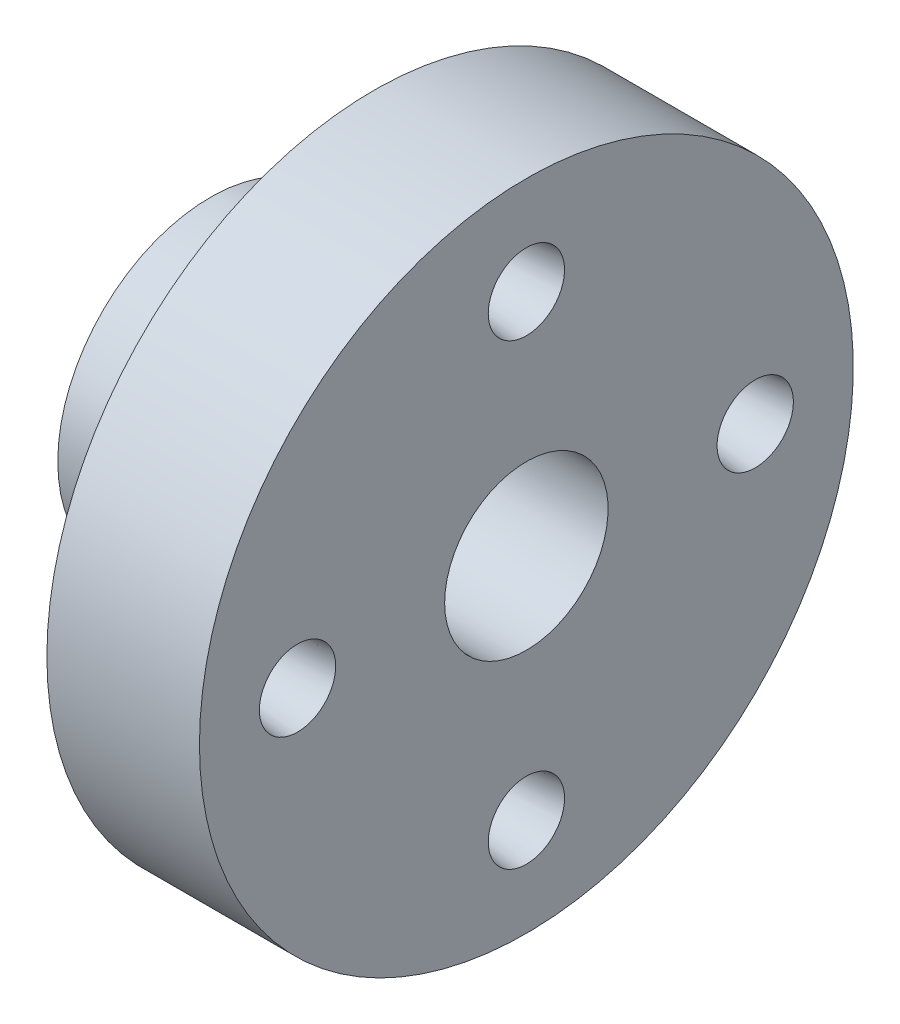
from build123d import *

# Parameters (mm, degrees)
PATTERN_CIRCULAR_2_COUNT = 4


with BuildPart() as part:
    # Эскиз1 → Повернуть1 (revolve)
    with BuildSketch(Plane.XY):
        Polygon((-29, -15), (29, -15), (29, -60), (1, -60), (1, -28), (-29, -28), align=None)
    revolve(axis=Axis((-59.74315319, 0, 0), (1, 0, 0)))

    # Эскиз3 → Вырез-Повернуть1 (revolve, cut)
    with BuildSketch(Plane.XY):
        Polygon((29, 42), (1, 42), (1, 47.7), (16, 47.7), (29, 49), align=None)
    cut_revolve_1 = revolve(axis=Axis((-8.793362521, 42, 0), (1, 0, 0)), mode=Mode.SUBTRACT)

    # Круговой массив2: Вырез-Повернуть1 ×4 about axis
    pattern_circular_2_axis = Axis((0, 0, 0), (1, 0, 0))
    for i in range(1, PATTERN_CIRCULAR_2_COUNT):
        add(cut_revolve_1.rotate(pattern_circular_2_axis, i * 360 / PATTERN_CIRCULAR_2_COUNT), mode=Mode.SUBTRACT)


solid = part.part
